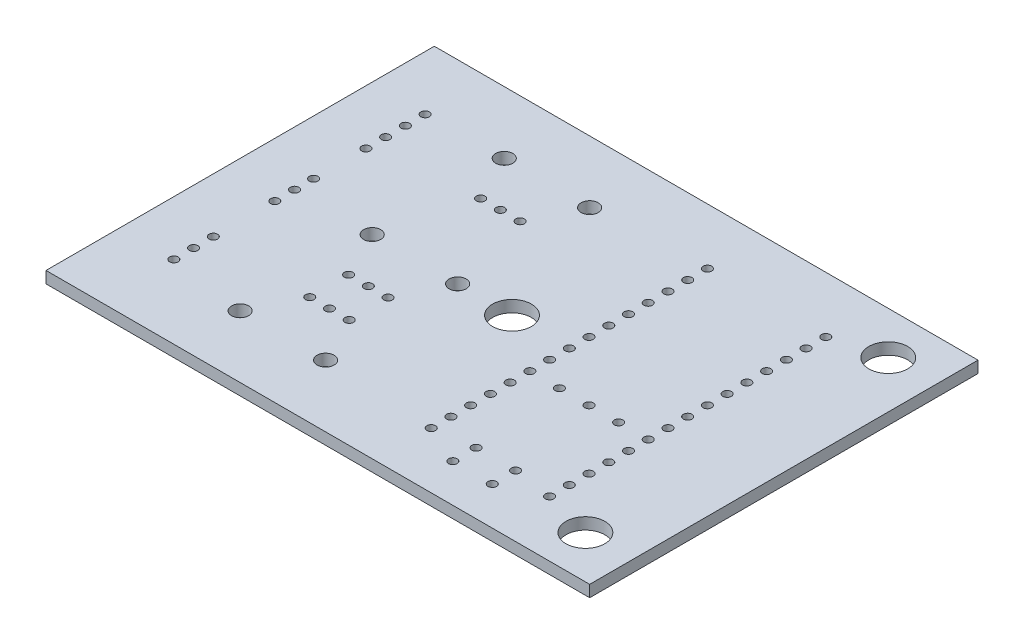
from build123d import *

# Parameters (mm, degrees)
SKETCH1_W           = 70
SKETCH1_H           = 50
BOSS_EXTRUDE1_DEPTH = 1.5
SKETCH2_R           = 2.5
CUT_EXTRUDE1_DEPTH  = 2.5
SKETCH4_R           = 1.1
SKETCH4_R_2         = 0.55
CUT_EXTRUDE2_DEPTH  = 2.5


with BuildPart() as part:
    # Sketch1 → Boss-Extrude1 (new body)
    with BuildSketch(Plane(origin=(0, 0, 0), x_dir=(1, 0, 0), z_dir=(0, 1, 0))):
        Rectangle(SKETCH1_W, SKETCH1_H)
    extrude(amount=BOSS_EXTRUDE1_DEPTH)

    # Sketch2 → Cut-Extrude1 (cut, through all)
    with BuildSketch(Plane(origin=(0, 1.5, 0), x_dir=(1, 0, 0), z_dir=(0, 1, 0))):
        Circle(SKETCH2_R)
        with Locations((28.95, 19.5)):
            Circle(SKETCH2_R)
        with Locations((28.95, -19.5)):
            Circle(SKETCH2_R)
    extrude(amount=-CUT_EXTRUDE1_DEPTH, mode=Mode.SUBTRACT)

    # Sketch4 → Cut-Extrude2 (cut, through all)
    with BuildSketch(Plane(origin=(0, 1.5, 0), x_dir=(1, 0, 0), z_dir=(0, 1, 0))):
        with Locations((-18, 0)):
            Circle(SKETCH4_R)
        with Locations((-7, 0)):
            Circle(SKETCH4_R)
        with Locations((-12.5, -6)):
            Circle(SKETCH4_R_2)
        with Locations((-9.96, -6)):
            Circle(SKETCH4_R_2)
        with Locations((-15.04, -6)):
            Circle(SKETCH4_R_2)
        with Locations((-12.5, 11)):
            Circle(SKETCH4_R_2)
        with Locations((-9.96, 11)):
            Circle(SKETCH4_R_2)
        with Locations((-15.04, 11)):
            Circle(SKETCH4_R_2)
        with Locations((-18, 17)):
            Circle(SKETCH4_R)
        with Locations((-7, 17)):
            Circle(SKETCH4_R)
        with Locations((-18, -17)):
            Circle(SKETCH4_R)
        with Locations((-7, -17)):
            Circle(SKETCH4_R)
        with Locations((7.38, 0)):
            Circle(SKETCH4_R_2)
        with Locations((22.62, 0)):
            Circle(SKETCH4_R_2)
        with Locations((7.38, 2.54)):
            Circle(SKETCH4_R_2)
        with Locations((7.38, 5.08)):
            Circle(SKETCH4_R_2)
        with Locations((7.38, 7.62)):
            Circle(SKETCH4_R_2)
        with Locations((7.38, 10.16)):
            Circle(SKETCH4_R_2)
        with Locations((7.38, 12.7)):
            Circle(SKETCH4_R_2)
        with Locations((7.38, 15.24)):
            Circle(SKETCH4_R_2)
        with Locations((7.38, 17.78)):
            Circle(SKETCH4_R_2)
        with Locations((22.62, 2.54)):
            Circle(SKETCH4_R_2)
        with Locations((22.62, 5.08)):
            Circle(SKETCH4_R_2)
        with Locations((22.62, 7.62)):
            Circle(SKETCH4_R_2)
        with Locations((22.62, 10.16)):
            Circle(SKETCH4_R_2)
        with Locations((22.62, 12.7)):
            Circle(SKETCH4_R_2)
        with Locations((22.62, 15.24)):
            Circle(SKETCH4_R_2)
        with Locations((22.62, 17.78)):
            Circle(SKETCH4_R_2)
        with Locations((22.62, -17.78)):
            Circle(SKETCH4_R_2)
        with Locations((22.62, -15.24)):
            Circle(SKETCH4_R_2)
        with Locations((22.62, -12.7)):
            Circle(SKETCH4_R_2)
        with Locations((22.62, -10.16)):
            Circle(SKETCH4_R_2)
        with Locations((22.62, -7.62)):
            Circle(SKETCH4_R_2)
        with Locations((22.62, -5.08)):
            Circle(SKETCH4_R_2)
        with Locations((22.62, -2.54)):
            Circle(SKETCH4_R_2)
        with Locations((7.38, -17.78)):
            Circle(SKETCH4_R_2)
        with Locations((7.38, -15.24)):
            Circle(SKETCH4_R_2)
        with Locations((7.38, -12.7)):
            Circle(SKETCH4_R_2)
        with Locations((7.38, -10.16)):
            Circle(SKETCH4_R_2)
        with Locations((7.38, -7.62)):
            Circle(SKETCH4_R_2)
        with Locations((7.38, -5.08)):
            Circle(SKETCH4_R_2)
        with Locations((7.38, -2.54)):
            Circle(SKETCH4_R_2)
        with Locations((-28, -13)):
            Circle(SKETCH4_R_2)
        with Locations((-28, -10.46)):
            Circle(SKETCH4_R_2)
        with Locations((-28, -15.54)):
            Circle(SKETCH4_R_2)
        with Locations((-28, 11.73)):
            Circle(SKETCH4_R_2)
        with Locations((-28, 14.27)):
            Circle(SKETCH4_R_2)
        with Locations((-28, 9.19)):
            Circle(SKETCH4_R_2)
        with Locations((-28, 16.81)):
            Circle(SKETCH4_R_2)
        with Locations((-9.96, -11)):
            Circle(SKETCH4_R_2)
        with Locations((-12.5, -11)):
            Circle(SKETCH4_R_2)
        with Locations((-15.04, -11)):
            Circle(SKETCH4_R_2)
        with Locations((11.19, -5.08)):
            Circle(SKETCH4_R_2)
        with Locations((15, -5.08)):
            Circle(SKETCH4_R_2)
        with Locations((18.81, -5.08)):
            Circle(SKETCH4_R_2)
        with Locations((12.46, -20.08)):
            Circle(SKETCH4_R_2)
        with Locations((17.54, -20.08)):
            Circle(SKETCH4_R_2)
        with Locations((17.54, -17.08)):
            Circle(SKETCH4_R_2)
        with Locations((-28, 0)):
            Circle(SKETCH4_R_2)
        with Locations((-28, -2.54)):
            Circle(SKETCH4_R_2)
        with Locations((-28, 2.45)):
            Circle(SKETCH4_R_2)
        with Locations((12.46, -17.08)):
            Circle(SKETCH4_R_2)
    extrude(amount=-CUT_EXTRUDE2_DEPTH, mode=Mode.SUBTRACT)


solid = part.part
